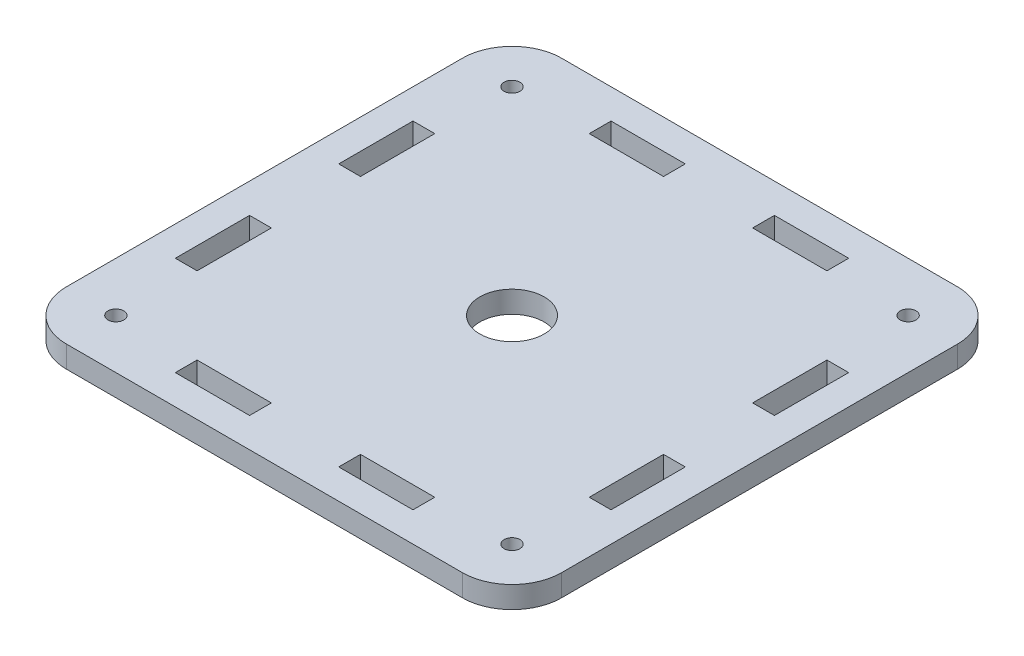
from build123d import *

# Parameters (mm, degrees)
SKETCH_1_W          = 100
SKETCH_1_H          = 100
SKETCH_1_R          = 6.5
EXTRUDE_1_DEPTH     = 4.4
FILLET_1_R          = 10
CUT_EXTRUDE_1_REACH = 6.4
SKETCH_2_R          = 1.6
SKETCH_2_W          = 15
SKETCH_2_H          = 4.4
SKETCH_2_W_2        = 4.4
SKETCH_2_H_2        = 15


with BuildPart() as part:
    # 草图1 → 凸台-拉伸1 (new body)
    with BuildSketch(Plane(origin=(0, 0, 0), x_dir=(1, 0, 0), z_dir=(0, 1, 0))):
        Rectangle(SKETCH_1_W, SKETCH_1_H)
        Circle(SKETCH_1_R, mode=Mode.SUBTRACT)
    extrude(amount=EXTRUDE_1_DEPTH)

    # 圆角1
    fillet_1_edges = [part.edges().sort_by_distance(p)[0] for p in [
        (50, 2.2, 50),
        (-50, 2.2, 50),
        (-50, 2.2, -50),
        (50, 2.2, -50),
    ]]
    fillet(fillet_1_edges, radius=FILLET_1_R)

    # 草图2 → 切除-拉伸1 (cut, up to next)
    with BuildSketch(Plane(origin=(0, 4.4, 0), x_dir=(1, 0, 0), z_dir=(0, 1, 0)), mode=Mode.PRIVATE) as cut_extrude_1_sk1:
        with Locations((40, 40)):
            Circle(SKETCH_2_R)
    cut_extrude_1_tool1 = extrude(cut_extrude_1_sk1.sketch, amount=-CUT_EXTRUDE_1_REACH, mode=Mode.PRIVATE) & part.part
    add(cut_extrude_1_tool1.solids().sort_by_distance((40, 4.4, -40))[0], mode=Mode.SUBTRACT)
    # 草图2 → 切除-拉伸1 (cut, up to next)
    with BuildSketch(Plane(origin=(0, 4.4, 0), x_dir=(1, 0, 0), z_dir=(0, 1, 0)), mode=Mode.PRIVATE) as cut_extrude_1_sk2:
        with Locations((40, -40)):
            Circle(SKETCH_2_R)
    cut_extrude_1_tool2 = extrude(cut_extrude_1_sk2.sketch, amount=-CUT_EXTRUDE_1_REACH, mode=Mode.PRIVATE) & part.part
    add(cut_extrude_1_tool2.solids().sort_by_distance((40, 4.4, 40))[0], mode=Mode.SUBTRACT)
    # 草图2 → 切除-拉伸1 (cut, up to next)
    with BuildSketch(Plane(origin=(0, 4.4, 0), x_dir=(1, 0, 0), z_dir=(0, 1, 0)), mode=Mode.PRIVATE) as cut_extrude_1_sk3:
        with Locations((-40, -40)):
            Circle(SKETCH_2_R)
    cut_extrude_1_tool3 = extrude(cut_extrude_1_sk3.sketch, amount=-CUT_EXTRUDE_1_REACH, mode=Mode.PRIVATE) & part.part
    add(cut_extrude_1_tool3.solids().sort_by_distance((-40, 4.4, 40))[0], mode=Mode.SUBTRACT)
    # 草图2 → 切除-拉伸1 (cut, up to next)
    with BuildSketch(Plane(origin=(0, 4.4, 0), x_dir=(1, 0, 0), z_dir=(0, 1, 0)), mode=Mode.PRIVATE) as cut_extrude_1_sk4:
        with Locations((-40, 40)):
            Circle(SKETCH_2_R)
    cut_extrude_1_tool4 = extrude(cut_extrude_1_sk4.sketch, amount=-CUT_EXTRUDE_1_REACH, mode=Mode.PRIVATE) & part.part
    add(cut_extrude_1_tool4.solids().sort_by_distance((-40, 4.4, -40))[0], mode=Mode.SUBTRACT)
    # 草图2 → 切除-拉伸1 (cut, up to next)
    with BuildSketch(Plane(origin=(0, 4.4, 0), x_dir=(1, 0, 0), z_dir=(0, 1, 0)), mode=Mode.PRIVATE) as cut_extrude_1_sk5:
        with Locations((-16.5, 41.8)):
            Rectangle(SKETCH_2_W, SKETCH_2_H)
    cut_extrude_1_tool5 = extrude(cut_extrude_1_sk5.sketch, amount=-CUT_EXTRUDE_1_REACH, mode=Mode.PRIVATE) & part.part
    add(cut_extrude_1_tool5.solids().sort_by_distance((-16.5, 4.4, -41.8))[0], mode=Mode.SUBTRACT)
    # 草图2 → 切除-拉伸1 (cut, up to next)
    with BuildSketch(Plane(origin=(0, 4.4, 0), x_dir=(1, 0, 0), z_dir=(0, 1, 0)), mode=Mode.PRIVATE) as cut_extrude_1_sk6:
        with Locations((16.5, 41.8)):
            Rectangle(SKETCH_2_W, SKETCH_2_H)
    cut_extrude_1_tool6 = extrude(cut_extrude_1_sk6.sketch, amount=-CUT_EXTRUDE_1_REACH, mode=Mode.PRIVATE) & part.part
    add(cut_extrude_1_tool6.solids().sort_by_distance((16.5, 4.4, -41.8))[0], mode=Mode.SUBTRACT)
    # 草图2 → 切除-拉伸1 (cut, up to next)
    with BuildSketch(Plane(origin=(0, 4.4, 0), x_dir=(1, 0, 0), z_dir=(0, 1, 0)), mode=Mode.PRIVATE) as cut_extrude_1_sk7:
        with Locations((41.8, -16.5)):
            Rectangle(SKETCH_2_W_2, SKETCH_2_H_2)
    cut_extrude_1_tool7 = extrude(cut_extrude_1_sk7.sketch, amount=-CUT_EXTRUDE_1_REACH, mode=Mode.PRIVATE) & part.part
    add(cut_extrude_1_tool7.solids().sort_by_distance((41.8, 4.4, 16.5))[0], mode=Mode.SUBTRACT)
    # 草图2 → 切除-拉伸1 (cut, up to next)
    with BuildSketch(Plane(origin=(0, 4.4, 0), x_dir=(1, 0, 0), z_dir=(0, 1, 0)), mode=Mode.PRIVATE) as cut_extrude_1_sk8:
        with Locations((41.8, 16.5)):
            Rectangle(SKETCH_2_W_2, SKETCH_2_H_2)
    cut_extrude_1_tool8 = extrude(cut_extrude_1_sk8.sketch, amount=-CUT_EXTRUDE_1_REACH, mode=Mode.PRIVATE) & part.part
    add(cut_extrude_1_tool8.solids().sort_by_distance((41.8, 4.4, -16.5))[0], mode=Mode.SUBTRACT)
    # 草图2 → 切除-拉伸1 (cut, up to next)
    with BuildSketch(Plane(origin=(0, 4.4, 0), x_dir=(1, 0, 0), z_dir=(0, 1, 0)), mode=Mode.PRIVATE) as cut_extrude_1_sk9:
        with Locations((-16.5, -41.8)):
            Rectangle(SKETCH_2_W, SKETCH_2_H)
    cut_extrude_1_tool9 = extrude(cut_extrude_1_sk9.sketch, amount=-CUT_EXTRUDE_1_REACH, mode=Mode.PRIVATE) & part.part
    add(cut_extrude_1_tool9.solids().sort_by_distance((-16.5, 4.4, 41.8))[0], mode=Mode.SUBTRACT)
    # 草图2 → 切除-拉伸1 (cut, up to next)
    with BuildSketch(Plane(origin=(0, 4.4, 0), x_dir=(1, 0, 0), z_dir=(0, 1, 0)), mode=Mode.PRIVATE) as cut_extrude_1_sk10:
        with Locations((16.5, -41.8)):
            Rectangle(SKETCH_2_W, SKETCH_2_H)
    cut_extrude_1_tool10 = extrude(cut_extrude_1_sk10.sketch, amount=-CUT_EXTRUDE_1_REACH, mode=Mode.PRIVATE) & part.part
    add(cut_extrude_1_tool10.solids().sort_by_distance((16.5, 4.4, 41.8))[0], mode=Mode.SUBTRACT)
    # 草图2 → 切除-拉伸1 (cut, up to next)
    with BuildSketch(Plane(origin=(0, 4.4, 0), x_dir=(1, 0, 0), z_dir=(0, 1, 0)), mode=Mode.PRIVATE) as cut_extrude_1_sk11:
        with Locations((-41.8, 16.5)):
            Rectangle(SKETCH_2_W_2, SKETCH_2_H_2)
    cut_extrude_1_tool11 = extrude(cut_extrude_1_sk11.sketch, amount=-CUT_EXTRUDE_1_REACH, mode=Mode.PRIVATE) & part.part
    add(cut_extrude_1_tool11.solids().sort_by_distance((-41.8, 4.4, -16.5))[0], mode=Mode.SUBTRACT)
    # 草图2 → 切除-拉伸1 (cut, up to next)
    with BuildSketch(Plane(origin=(0, 4.4, 0), x_dir=(1, 0, 0), z_dir=(0, 1, 0)), mode=Mode.PRIVATE) as cut_extrude_1_sk12:
        with Locations((-41.8, -16.5)):
            Rectangle(SKETCH_2_W_2, SKETCH_2_H_2)
    cut_extrude_1_tool12 = extrude(cut_extrude_1_sk12.sketch, amount=-CUT_EXTRUDE_1_REACH, mode=Mode.PRIVATE) & part.part
    add(cut_extrude_1_tool12.solids().sort_by_distance((-41.8, 4.4, 16.5))[0], mode=Mode.SUBTRACT)


solid = part.part
